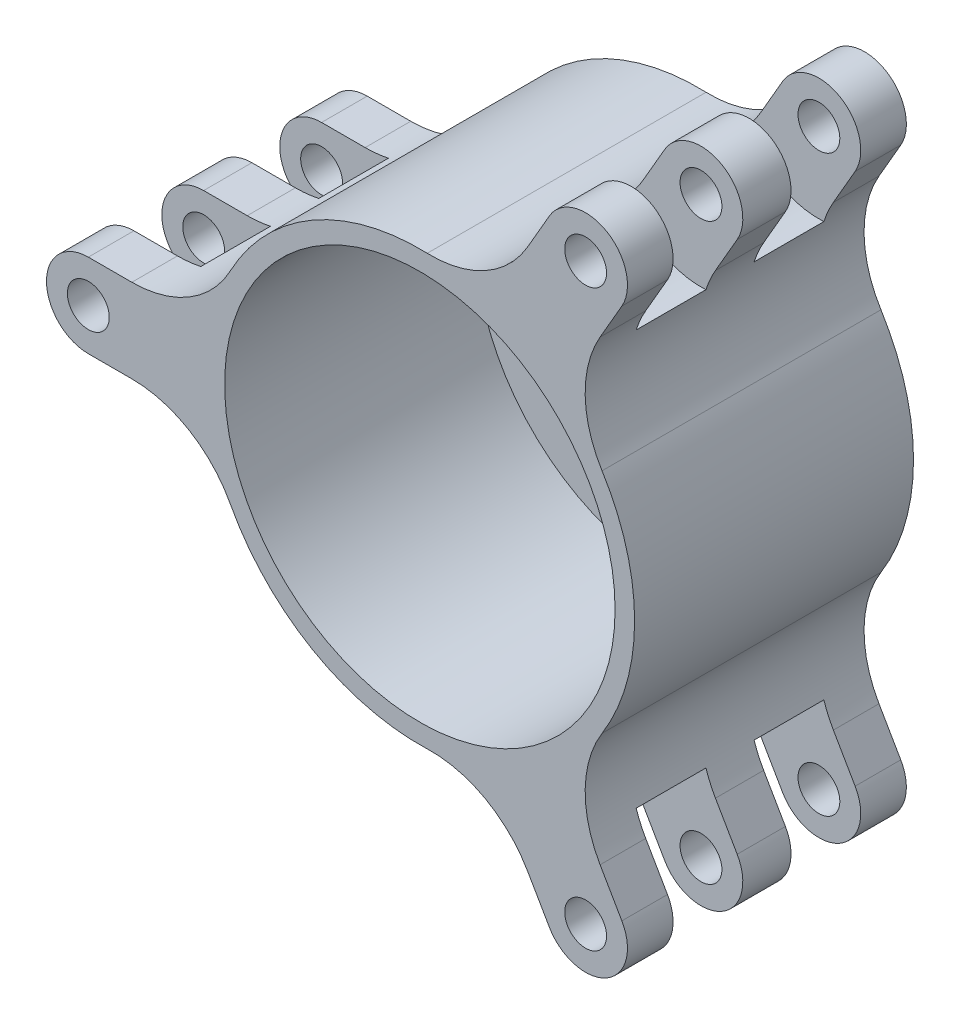
from build123d import *

# Parameters (mm, degrees)
SKETCH1_R                 = 15.4
BOSS_EXTRUDE1_DEPTH       = 20
BOSS_EXTRUDE2_DEPTH       = 20
FILLET4_R                 = 8
CIRPATTERN11_COUNT        = 3
FILLET4_OF_CIRPATTERN11_R = 8
SKETCH4_R                 = 14
CUT_EXTRUDE3_DEPTH        = 18
SKETCH5_R                 = 5
CUT_EXTRUDE4_DEPTH        = 19
CUT_EXTRUDE4_DEPTH_BACK   = 3
CUT_EXTRUDE5_START        = -3
SKETCH7_R                 = 3
CUT_EXTRUDE5_DEPTH        = 22
CIRPATTERN12_COUNT        = 4
CUT_EXTRUDE1_START        = -21
SKETCH2_R                 = 1.5
CUT_EXTRUDE1_DEPTH        = 22
CIRPATTERN10_COUNT        = 3
SKETCH3_R                 = 5.75
CUT_EXTRUDE2_DEPTH        = 2.5
CIRPATTERN3_COUNT         = 3
MIRROR1_COPY_1_SKETCH_R   = 5.75
MIRROR1_COPY_1_DEPTH      = 2.5
MIRROR1_COPY_2_SKETCH_R   = 5.75
MIRROR1_COPY_2_DEPTH      = 2.5


with BuildPart() as part:
    # Sketch1 → Boss-Extrude1 (new body)
    with BuildSketch(Plane.XY):
        Circle(SKETCH1_R)
    extrude(amount=BOSS_EXTRUDE1_DEPTH)

    # Sketch6 → Boss-Extrude2 (add)
    with BuildSketch(Plane.XY.offset(20)):
        with BuildLine():
            Line((-23.775, 3), (-15.104966071, 3))
            ThreePointArc((-15.104966071, 3), (-15.4, 0), (-15.104966071, -3))
            Line((-15.104966071, -3), (-23.775, -3))
            ThreePointArc((-23.775, -3), (-26.775, 0), (-23.775, 3))
        make_face()
    boss_extrude2 = extrude(amount=-BOSS_EXTRUDE2_DEPTH)

    # Fillet4
    fillet4_edges = [part.edges().sort_by_distance(p)[0] for p in [
        (-15.104966071, 3, 10),
        (-15.104966071, -3, 10),
    ]]
    fillet(fillet4_edges, radius=FILLET4_R)

    # CirPattern11: Boss-Extrude2 ×3 about axis
    cirpattern11_axis = Axis((0, 0, 0), (0, 0, 1))
    for i in range(1, CIRPATTERN11_COUNT):
        add(boss_extrude2.rotate(cirpattern11_axis, i * 360 / CIRPATTERN11_COUNT))

    # Fillet4 of CirPattern11
    fillet4_of_cirpattern11_edges = [part.edges().sort_by_distance(p)[0] for p in [
        (4.954406824, -14.581284341, 10),
        (10.150559247, -11.581284341, 10),
        (10.150559247, 11.581284341, 10),
        (4.954406824, 14.581284341, 10),
    ]]
    fillet(fillet4_of_cirpattern11_edges, radius=FILLET4_OF_CIRPATTERN11_R)

    # Sketch4 → Cut-Extrude3 (cut)
    with BuildSketch(Plane.XY.offset(20)):
        Circle(SKETCH4_R)
    extrude(amount=-CUT_EXTRUDE3_DEPTH, mode=Mode.SUBTRACT)

    # Sketch5 → Cut-Extrude4 (cut, two sides)
    with BuildSketch(Plane.XY.offset(2)) as cut_extrude4_sk:
        Circle(SKETCH5_R)
    extrude(amount=CUT_EXTRUDE4_DEPTH, mode=Mode.SUBTRACT)
    extrude(cut_extrude4_sk.sketch, amount=-CUT_EXTRUDE4_DEPTH_BACK, mode=Mode.SUBTRACT)

    # Sketch7 → Cut-Extrude5 (cut)
    with BuildSketch(Plane.XY.offset(2).offset(CUT_EXTRUDE5_START)):
        with Locations((-8.4, 0)):
            Circle(SKETCH7_R)
    cut_extrude5 = extrude(amount=CUT_EXTRUDE5_DEPTH, mode=Mode.SUBTRACT)

    # CirPattern12: Cut-Extrude5 ×4 about axis
    cirpattern12_axis = Axis((0, 0, 0), (0, 0, 1))
    for i in range(1, CIRPATTERN12_COUNT):
        add(cut_extrude5.rotate(cirpattern12_axis, i * 360 / CIRPATTERN12_COUNT), mode=Mode.SUBTRACT)

    # Sketch2 → Cut-Extrude1 (cut)
    with BuildSketch(Plane.XY.offset(20).offset(CUT_EXTRUDE1_START)):
        with Locations((-23.775, 0)):
            Circle(SKETCH2_R)
    cut_extrude1 = extrude(amount=CUT_EXTRUDE1_DEPTH, mode=Mode.SUBTRACT)

    # CirPattern10: Cut-Extrude1 ×3 about axis
    cirpattern10_axis = Axis((0, 0, 0), (0, 0, 1))
    for i in range(1, CIRPATTERN10_COUNT):
        add(cut_extrude1.rotate(cirpattern10_axis, i * 360 / CIRPATTERN10_COUNT), mode=Mode.SUBTRACT)

    # Sketch3 → Cut-Extrude2 (cut, symmetric)
    with BuildSketch(Plane.XY.offset(5.771567898)):
        with Locations((-23.775, 0)):
            Circle(SKETCH3_R)
    cut_extrude2 = extrude(amount=CUT_EXTRUDE2_DEPTH, both=True, mode=Mode.SUBTRACT)

    # CirPattern3: Cut-Extrude2 ×3 about axis
    cirpattern3_axis = Axis((0, 0, 0), (0, 0, 1))
    for i in range(1, CIRPATTERN3_COUNT):
        add(cut_extrude2.rotate(cirpattern3_axis, i * 360 / CIRPATTERN3_COUNT), mode=Mode.SUBTRACT)

    # Mirror1: Cut-Extrude2 across plane
    add(cut_extrude2.mirror(Plane.XY.offset(10)), mode=Mode.SUBTRACT)

    # Mirror1 copy 1 sketch → Mirror1 copy 1 (cut, symmetric)
    with BuildSketch(Plane(origin=(0, 0, 14.228432102), x_dir=(-0.5, 0.866025404, 0), z_dir=(0, 0, -1))):
        with Locations((-23.775, 0)):
            Circle(MIRROR1_COPY_1_SKETCH_R)
    extrude(amount=MIRROR1_COPY_1_DEPTH, both=True, mode=Mode.SUBTRACT)

    # Mirror1 copy 2 sketch → Mirror1 copy 2 (cut, symmetric)
    with BuildSketch(Plane(origin=(0, 0, 14.228432102), x_dir=(-0.5, -0.866025404, 0), z_dir=(0, 0, -1))):
        with Locations((-23.775, 0)):
            Circle(MIRROR1_COPY_2_SKETCH_R)
    extrude(amount=MIRROR1_COPY_2_DEPTH, both=True, mode=Mode.SUBTRACT)


solid = part.part
